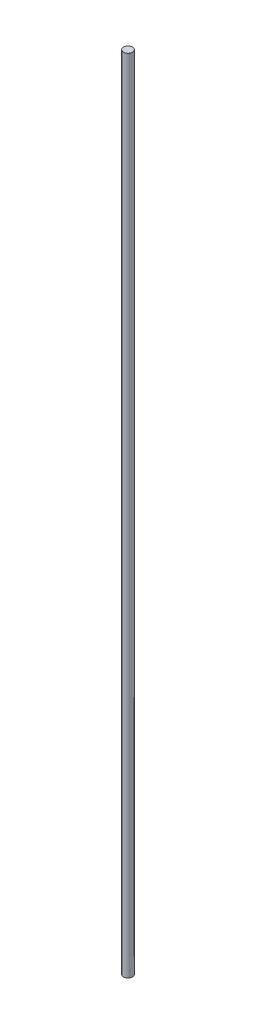
from build123d import *

# Parameters (mm, degrees)
SKETCH1_R           = 0.2125
BOSS_EXTRUDE1_DEPTH = 38.1


with BuildPart() as part:
    # Sketch1 → Boss-Extrude1 (new body)
    with BuildSketch(Plane(origin=(0, 0, 0), x_dir=(1, 0, 0), z_dir=(0, 1, 0))):
        Circle(SKETCH1_R)
    extrude(amount=BOSS_EXTRUDE1_DEPTH)


solid = part.part
